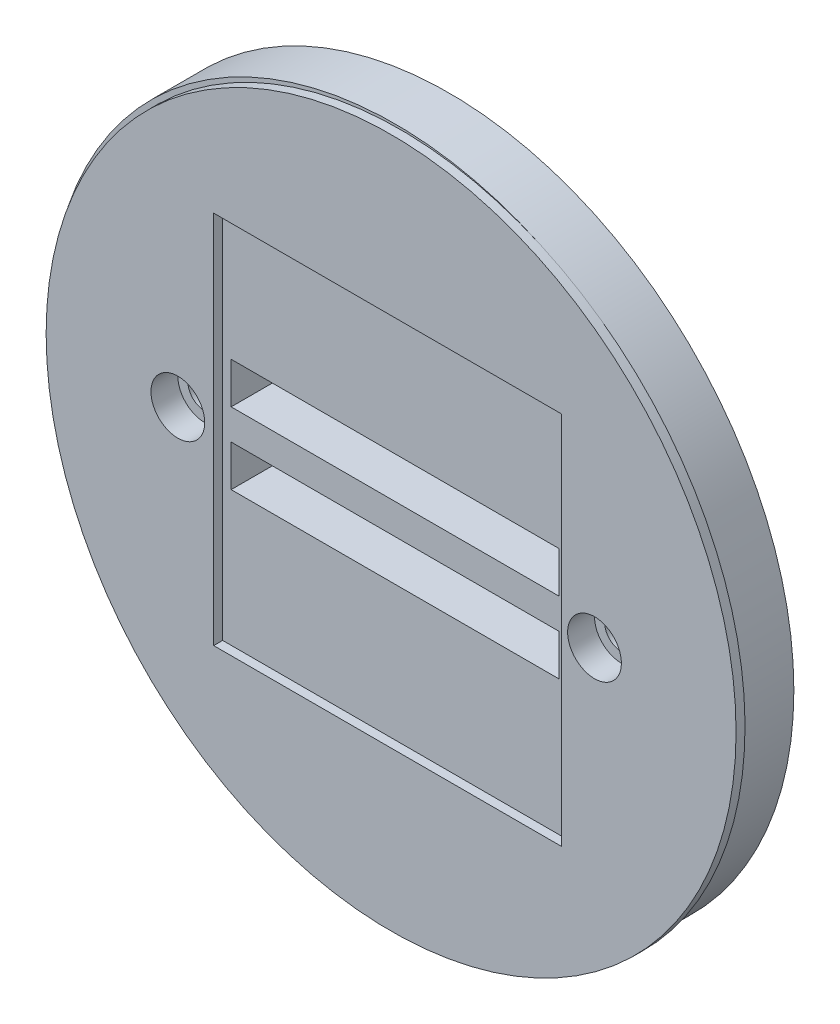
from build123d import *

# Parameters (mm, degrees)
SKETCH1_R                  = 38.5
SKETCH1_R_2                = 1.875
SKETCH1_W                  = 36.6
SKETCH1_H                  = 4.6
MAIN_FLANGE_COUPLING_DEPTH = 6
SKETCH2_R                  = 38.5
SKETCH2_R_2                = 1.65
SKETCH2_W                  = 38.8
SKETCH2_H                  = 41.8
BOSS_EXTRUDE1_DEPTH        = 1
SKETCH3_R                  = 3
CUT_EXTRUDE1_DEPTH         = 3


with BuildPart() as part:
    # Sketch1 → Main Flange Coupling (new body)
    with BuildSketch(Plane.XY):
        Circle(SKETCH1_R)
        with Locations((-23.25, 0)):
            Circle(SKETCH1_R_2, mode=Mode.SUBTRACT)
        with Locations((23.25, 0)):
            Circle(SKETCH1_R_2, mode=Mode.SUBTRACT)
        with Locations((0, 4.3)):
            Rectangle(SKETCH1_W, SKETCH1_H, mode=Mode.SUBTRACT)
        with Locations((0, -3.7)):
            Rectangle(SKETCH1_W, SKETCH1_H, mode=Mode.SUBTRACT)
    extrude(amount=-MAIN_FLANGE_COUPLING_DEPTH)

    # Sketch2 → Boss-Extrude1 (add)
    with BuildSketch(Plane.XY):
        with Locations((0.55, -0.25)):
            Circle(SKETCH2_R)
        with Locations((-23.25, 0)):
            Circle(SKETCH2_R_2, mode=Mode.SUBTRACT)
        with Locations((23.25, 0)):
            Circle(SKETCH2_R_2, mode=Mode.SUBTRACT)
        with Locations((0.15, -0.15)):
            Rectangle(SKETCH2_W, SKETCH2_H, mode=Mode.SUBTRACT)
    extrude(amount=BOSS_EXTRUDE1_DEPTH)

    # Sketch3 → Cut-Extrude1 (cut)
    with BuildSketch(Plane.XY.offset(1)):
        with Locations((-23.25, 0)):
            Circle(SKETCH3_R)
        with Locations((23.25, 0)):
            Circle(SKETCH3_R)
    extrude(amount=-CUT_EXTRUDE1_DEPTH, mode=Mode.SUBTRACT)


solid = part.part
